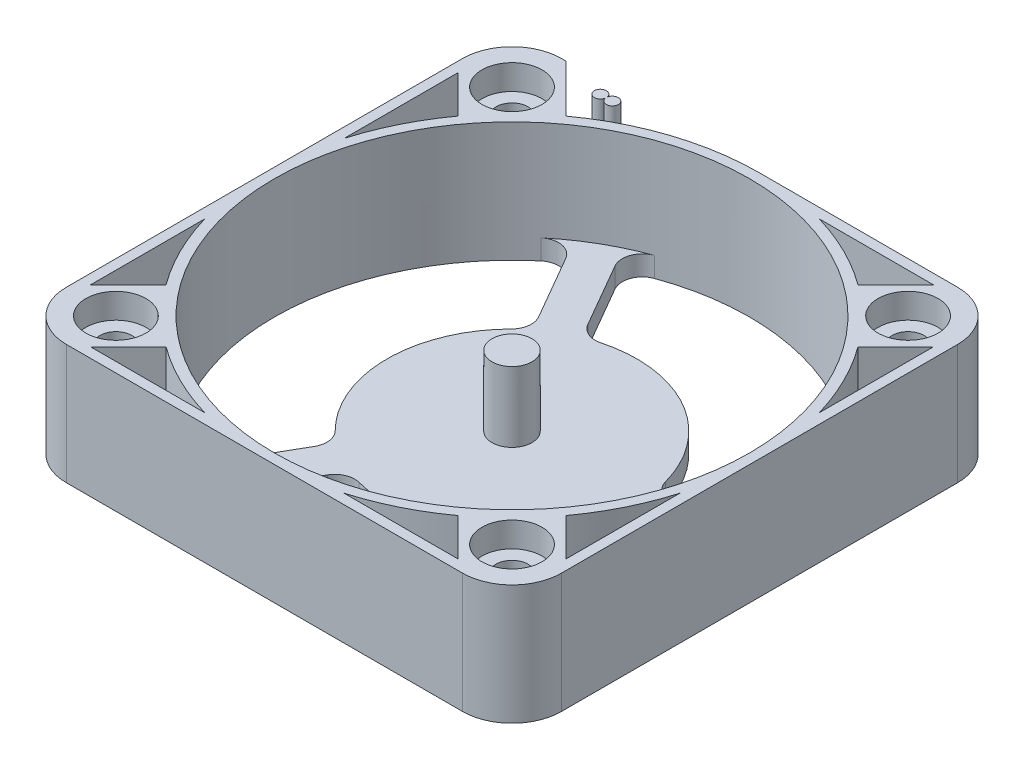
from build123d import *

# Parameters (mm, degrees)
SKETCH_1_W                       = 49.5
SKETCH_1_H                       = 49.5
SKETCH_1_R                       = 23.75
EXTRUDE_1_DEPTH                  = 11.98
SKETCH_2_R                       = 3
CUT_EXTRUDE_1_DEPTH              = 2.5
SKETCH_3_R                       = 1.6
CUT_EXTRUDE_2_DEPTH              = 10.48
CUT_EXTRUDE_3_DEPTH              = 12.98
CUT_EXTRUDE_4_DEPTH              = 9.5
PATTERN_CIRCULAR_1_COUNT         = 4
SKETCH_7_R                       = 12.5
EXTRUDE_2_DEPTH                  = 2
EXTRUDE_3_DEPTH                  = 2
FILLET_2_R                       = 2
PATTERN_CIRCULAR_2_COUNT         = 3
FILLET_2_OF_PATTERN_CIRCULAR_2_R = 2
SKETCH_9_R                       = 2
EXTRUDE_4_DEPTH                  = 7
CUT_EXTRUDE_5_DEPTH              = 9.5
EXTRUDE_5_DEPTH                  = 10


with BuildPart() as part:
    # 草图1 → 凸台-拉伸1 (new body)
    with BuildSketch(Plane(origin=(0, 0, 0), x_dir=(1, 0, 0), z_dir=(0, 1, 0))):
        Rectangle(SKETCH_1_W, SKETCH_1_H)
        Circle(SKETCH_1_R, mode=Mode.SUBTRACT)
    extrude(amount=EXTRUDE_1_DEPTH)

    # 草图2 → 切除-拉伸1 (cut)
    with BuildSketch(Plane(origin=(0, 11.98, 0), x_dir=(1, 0, 0), z_dir=(0, 1, 0))):
        with Locations((-19.798989873, 19.798989873)):
            Circle(SKETCH_2_R)
    cut_extrude_1 = extrude(amount=-CUT_EXTRUDE_1_DEPTH, mode=Mode.SUBTRACT)

    # 草图3 → 切除-拉伸2 (cut, through all)
    with BuildSketch(Plane(origin=(0, 9.48, 0), x_dir=(1, 0, 0), z_dir=(0, 1, 0))):
        with Locations((-19.798989873, 19.798989873)):
            Circle(SKETCH_3_R)
    cut_extrude_2 = extrude(amount=-CUT_EXTRUDE_2_DEPTH, mode=Mode.SUBTRACT)

    # 草图4 → 切除-拉伸3 (cut, through all)
    with BuildSketch(Plane(origin=(0, 11.98, 0), x_dir=(1, 0, 0), z_dir=(0, 1, 0))):
        with BuildLine():
            Line((-24.75, 19.798989873), (-24.75, 24.75))
            Line((-24.75, 24.75), (-19.798989873, 24.75))
            ThreePointArc((-19.798989873, 24.75), (-23.299882708, 23.299882708), (-24.75, 19.798989873))
        make_face()
    cut_extrude_3 = extrude(amount=-CUT_EXTRUDE_3_DEPTH, mode=Mode.SUBTRACT)

    # 草图5 → 切除-拉伸4 (cut)
    with BuildSketch(Plane(origin=(0, 11.98, 0), x_dir=(1, 0, 0), z_dir=(0, 1, 0))):
        with BuildLine():
            Line((-23.75, 18.375988463), (-19.980393233, 14.606381696))
            ThreePointArc((-19.980393233, 14.606381696), (-22.196566868, 10.948740533), (-23.75, 6.964194139))
            Line((-23.75, 6.964194139), (-23.75, 18.375988463))
        make_face()
        with BuildLine():
            Line((-18.375988463, 23.75), (-6.964194139, 23.75))
            ThreePointArc((-6.964194139, 23.75), (-10.948740533, 22.196566868), (-14.606381696, 19.980393233))
            Line((-14.606381696, 19.980393233), (-18.375988463, 23.75))
        make_face()
    cut_extrude_4 = extrude(amount=-CUT_EXTRUDE_4_DEPTH, mode=Mode.SUBTRACT)

    # 阵列(圆周)1: 切除-拉伸1, 切除-拉伸2, 切除-拉伸3, 切除-拉伸4 ×4 about axis
    pattern_circular_1_axis = Axis((0, 0, 0), (0, 1, 0))
    for i in range(1, PATTERN_CIRCULAR_1_COUNT):
        add(cut_extrude_1.rotate(pattern_circular_1_axis, i * 360 / PATTERN_CIRCULAR_1_COUNT), mode=Mode.SUBTRACT)
        add(cut_extrude_2.rotate(pattern_circular_1_axis, i * 360 / PATTERN_CIRCULAR_1_COUNT), mode=Mode.SUBTRACT)
        add(cut_extrude_3.rotate(pattern_circular_1_axis, i * 360 / PATTERN_CIRCULAR_1_COUNT), mode=Mode.SUBTRACT)
        add(cut_extrude_4.rotate(pattern_circular_1_axis, i * 360 / PATTERN_CIRCULAR_1_COUNT), mode=Mode.SUBTRACT)



with BuildPart() as body_2:
    # 草图7 → 凸台-拉伸2 (new body)
    with BuildSketch(Plane.XZ):
        Circle(SKETCH_7_R)
    extrude(amount=-EXTRUDE_2_DEPTH)


with BuildPart() as part_1:
    add(part.part)

    add(body_2.part)  # 凸台-拉伸3 merges body 2
    # 草图8 → 凸台-拉伸3 (add)
    with BuildSketch(Plane.XZ):
        with BuildLine():
            Line((23.68169124, -1.8), (12.369721096, -1.8))
            ThreePointArc((12.369721096, -1.8), (12.5, 0), (12.369721096, 1.8))
            Line((12.369721096, 1.8), (23.68169124, 1.8))
            ThreePointArc((23.68169124, 1.8), (23.75, 0), (23.68169124, -1.8))
        make_face()
    extrude_3 = extrude(amount=-EXTRUDE_3_DEPTH)

    # 圆角2
    fillet_2_edges = [part_1.edges().sort_by_distance(p)[0] for p in [
        (23.68169124, 1, 1.8),
        (23.68169124, 1, -1.8),
        (12.369721096, 1, -1.8),
        (12.369721096, 1, 1.8),
    ]]
    fillet(fillet_2_edges, radius=FILLET_2_R)

    # 阵列(圆周)2: 凸台-拉伸3 ×3 about axis
    pattern_circular_2_axis = Axis((0, 0, 0), (0, 1, 0))
    for i in range(1, PATTERN_CIRCULAR_2_COUNT):
        add(extrude_3.rotate(pattern_circular_2_axis, i * 360 / PATTERN_CIRCULAR_2_COUNT))

    # 圆角2 of 阵列(圆周)2
    fillet_2_of_pattern_circular_2_edges = [part_1.edges().sort_by_distance(p)[0] for p in [
        (-10.281999893, 1, -21.408946219),
        (-13.399691347, 1, -19.608946219),
        (-7.743706275, 1, -9.812492707),
        (-4.626014821, 1, -11.612492707),
        (-13.399691347, 1, 19.608946219),
        (-10.281999893, 1, 21.408946219),
        (-4.626014821, 1, 11.612492707),
        (-7.743706275, 1, 9.812492707),
    ]]
    fillet(fillet_2_of_pattern_circular_2_edges, radius=FILLET_2_OF_PATTERN_CIRCULAR_2_R)

    # 草图9 → 凸台-拉伸4 (add)
    with BuildSketch(Plane(origin=(0, 2, 0), x_dir=(1, 0, 0), z_dir=(0, 1, 0))):
        Circle(SKETCH_9_R)
    extrude(amount=EXTRUDE_4_DEPTH)

    # 草图10 → 切除-拉伸5 (cut)
    with BuildSketch(Plane(origin=(0, 11.98, 0), x_dir=(1, 0, 0), z_dir=(0, 1, 0))):
        with BuildLine():
            Line((-14.606381696, 19.980393233), (-19.375988463, 24.75))
            Line((-19.375988463, 24.75), (0, 24.75))
            ThreePointArc((0, 24.75), (-7.68270029, 23.527401392), (-14.606381696, 19.980393233))
        make_face()
    extrude(amount=-CUT_EXTRUDE_5_DEPTH, mode=Mode.SUBTRACT)

    # 草图11 → 凸台-拉伸5 (add)
    with BuildSketch(Plane(origin=(0, 2.48, 0), x_dir=(1, 0, 0), z_dir=(0, 1, 0))):
        with BuildLine():
            Line((-13.662941725, 23.240819528), (-13.691818706, 23.240819528))
            ThreePointArc((-13.691818706, 23.240819528), (-14.877380215, 23.109984827), (-13.691818706, 22.979150126))
            Line((-13.691818706, 22.979150126), (-13.662941725, 22.979150126))
            ThreePointArc((-13.662941725, 22.979150126), (-12.477380215, 23.109984827), (-13.662941725, 23.240819528))
        make_face()
    extrude(amount=EXTRUDE_5_DEPTH)


solid = part_1.part
